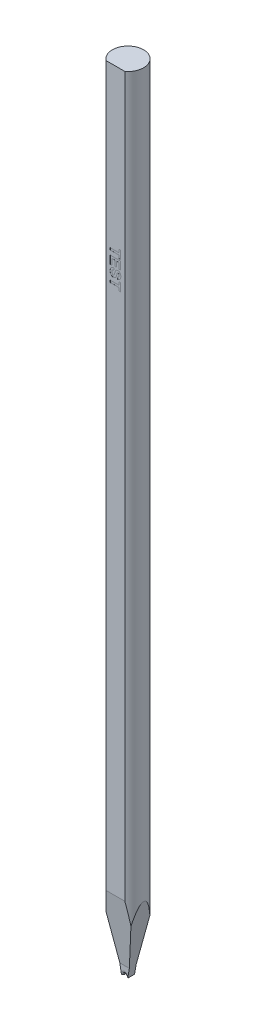
from build123d import *

# Parameters (mm, degrees)
SKETCH_TL_CUTTING_R       = 1.4986
TL_CUTTING_DEPTH          = 75.9968
SKETCH_TDF_GRINDING_W     = 3.0172
SKETCH_TDF_GRINDING_H     = 3.0172
TDF_GRINDING_DEPTH        = 76.9968
ENGRAVING_DEPTH           = 0.005
VW_VR_GRINDING_DEPTH      = 1.5086
VW_VR_GRINDING_DEPTH_BACK = 1.5086
ISA_GRINDING_DEPTH        = 1.5086
ISA_GRINDING_DEPTH_BACK   = 1.5086
SKETCH_PRE_FRX_BRX_W      = 1.18348
SKETCH_PRE_FRX_BRX_H      = 0.889
PRE_FRX_BRX_DEPTH         = 1.5086
PRE_FRX_BRX_DEPTH_BACK    = 1.5086
FR_EDM_R                  = 0.22606
BR_EDM_R                  = 0.22606
FA_BA_GRINDING_DEPTH      = 1.5086
FA_BA_GRINDING_DEPTH_BACK = 1.5086


with BuildPart() as part:
    # sketch_TL_cutting → TL_cutting (new body)
    with BuildSketch(Plane(origin=(0, 0, 0), x_dir=(1, 0, 0), z_dir=(0, 1, 0))):
        Circle(SKETCH_TL_CUTTING_R)
    extrude(amount=TL_CUTTING_DEPTH)

    # sketch_TDF_grinding → TDF_grinding (cut, through all)
    with BuildSketch(Plane(origin=(0, 0, 0), x_dir=(1, 0, 0), z_dir=(0, 1, 0))):
        with Locations((0, -2.71002)):
            Rectangle(SKETCH_TDF_GRINDING_W, SKETCH_TDF_GRINDING_H)
    extrude(amount=TDF_GRINDING_DEPTH, mode=Mode.SUBTRACT)

    # sketch_engraving → engraving (cut)
    with BuildSketch(Plane.XY.offset(1.20142)):
        Polygon((-0.5, 60.663467), (0.333333, 60.663467), (0.333333, 60.958338), (0.5, 60.958338), (0.5, 60.176287), (0.333333, 60.176287), (0.333333, 60.471159), (-0.5, 60.471159), align=None)
        Polygon((-0.5, 60.048082), (0.5, 60.048082), (0.5, 59.304492), (0.333333, 59.304492), (0.333333, 59.855774), (0.115385, 59.855774), (0.115385, 59.342954), (-0.051282, 59.342954), (-0.051282, 59.855774), (-0.333333, 59.855774), (-0.333333, 59.291672), (-0.5, 59.291672), align=None)
        with BuildLine():
            Line((-0.166667, 59.176287), (-0.153846, 58.983979))
            add(Edge.make_bspline(
                [(-0.153846, 58.983979), (-0.161891, 58.982447), (-0.177518, 58.97947), (-0.199795, 58.972866), (-0.220542, 58.96556), (-0.239663, 58.956947), (-0.257106, 58.947082), (-0.273157, 58.936291), (-0.287328, 58.924049), (-0.299925, 58.910717), (-0.310783, 58.896144), (-0.320246, 58.880443), (-0.328256, 58.863522), (-0.334922, 58.845445), (-0.339885, 58.826031), (-0.34342, 58.805464), (-0.345683, 58.783709), (-0.345994, 58.768841), (-0.346154, 58.761223)],
                knots=[0, 0, 0, 0, 2.5e-05, 4.8e-05, 7e-05, 9.1e-05, 0.000111, 0.00013, 0.000148, 0.000167, 0.000185, 0.000203, 0.000221, 0.000241, 0.000261, 0.000281, 0.000303, 0.000326, 0.000326, 0.000326, 0.000326], degree=3))
            add(Edge.make_bspline(
                [(-0.346154, 58.761223), (-0.346066, 58.753205), (-0.345896, 58.737609), (-0.343785, 58.715008), (-0.340761, 58.693876), (-0.335974, 58.674398), (-0.330621, 58.656212), (-0.323297, 58.639767), (-0.314849, 58.624799), (-0.305264, 58.611347), (-0.294632, 58.599606), (-0.283534, 58.589335), (-0.272208, 58.58039), (-0.260151, 58.573349), (-0.247852, 58.567651), (-0.234944, 58.563885), (-0.221722, 58.561341), (-0.212686, 58.56105), (-0.208133, 58.560903)],
                knots=[0, 0, 0, 0, 2.4e-05, 4.7e-05, 6.8e-05, 8.8e-05, 0.000107, 0.000125, 0.000142, 0.000158, 0.000174, 0.000189, 0.000204, 0.000217, 0.000231, 0.000244, 0.000258, 0.000271, 0.000271, 0.000271, 0.000271], degree=3))
            add(Edge.make_bspline(
                [(-0.208133, 58.560903), (-0.202439, 58.561197), (-0.191321, 58.561771), (-0.175221, 58.565542), (-0.160659, 58.572346), (-0.147071, 58.581583), (-0.134927, 58.594547), (-0.12346, 58.610951), (-0.113169, 58.631411), (-0.107424, 58.64658), (-0.104367, 58.654653)],
                knots=[0, 0, 0, 0, 1.7e-05, 3.3e-05, 4.9e-05, 6.5e-05, 8.2e-05, 0.000102, 0.000125, 0.000151, 0.000151, 0.000151, 0.000151], degree=3))
            add(Edge.make_bspline(
                [(-0.104367, 58.654653), (-0.103206, 58.658117), (-0.100608, 58.665869), (-0.096897, 58.679095), (-0.092218, 58.69508), (-0.087053, 58.713974), (-0.081545, 58.735737), (-0.074956, 58.760162), (-0.068334, 58.787622), (-0.063456, 58.806835), (-0.060897, 58.816912)],
                knots=[0, 0, 0, 0, 1.1e-05, 2.5e-05, 4.1e-05, 6.1e-05, 8.3e-05, 0.000109, 0.000137, 0.000168, 0.000168, 0.000168, 0.000168], degree=3))
            add(Edge.make_bspline(
                [(-0.060897, 58.816912), (-0.057621, 58.830036), (-0.051299, 58.855355), (-0.040053, 58.891467), (-0.02888, 58.924727), (-0.016756, 58.954814), (-0.004503, 58.98206), (0.008738, 59.006026), (0.02228, 59.02721), (0.032402, 59.039554), (0.03726, 59.045478)],
                knots=[0, 0, 0, 0, 4.1e-05, 7.8e-05, 0.000113, 0.000146, 0.000176, 0.000203, 0.000228, 0.000251, 0.000251, 0.000251, 0.000251], degree=3))
            add(Edge.make_bspline(
                [(0.03726, 59.045478), (0.044138, 59.052824), (0.057623, 59.067227), (0.079781, 59.086185), (0.103188, 59.102116), (0.127671, 59.115229), (0.15337, 59.125325), (0.180114, 59.132481), (0.207972, 59.137113), (0.226945, 59.137586), (0.236579, 59.137826)],
                knots=[0, 0, 0, 0, 3e-05, 5.9e-05, 8.7e-05, 0.000115, 0.000142, 0.00017, 0.000198, 0.000227, 0.000227, 0.000227, 0.000227], degree=3))
            add(Edge.make_bspline(
                [(0.236579, 59.137826), (0.249045, 59.137358), (0.273774, 59.136431), (0.310123, 59.127929), (0.345194, 59.11468), (0.373053, 59.099328), (0.394102, 59.084549), (0.409316, 59.072323), (0.423235, 59.058633), (0.436363, 59.043971), (0.448421, 59.028092), (0.459337, 59.010976), (0.469762, 58.992944), (0.481724, 58.966632), (0.494502, 58.931101), (0.505217, 58.884866), (0.51162, 58.83452), (0.512411, 58.799571), (0.512821, 58.781455)],
                knots=[0, 0, 0, 0, 3.7e-05, 7.4e-05, 0.000111, 0.00015, 0.000169, 0.000188, 0.000208, 0.000228, 0.000247, 0.000268, 0.000288, 0.00031, 0.000354, 0.000402, 0.000452, 0.000506, 0.000506, 0.000506, 0.000506], degree=3))
            add(Edge.make_bspline(
                [(0.512821, 58.781455), (0.512623, 58.766622), (0.512239, 58.737772), (0.508327, 58.695955), (0.502301, 58.656946), (0.493472, 58.620811), (0.482081, 58.587482), (0.468308, 58.556893), (0.452029, 58.529125), (0.433078, 58.504473), (0.412189, 58.48251), (0.389372, 58.463351), (0.364915, 58.446922), (0.338835, 58.433118), (0.311, 58.422277), (0.281444, 58.414315), (0.250236, 58.409049), (0.228852, 58.407729), (0.217949, 58.407056)],
                knots=[0, 0, 0, 0, 4.4e-05, 8.7e-05, 0.000126, 0.000163, 0.000198, 0.000231, 0.000263, 0.000294, 0.000324, 0.000354, 0.000383, 0.000413, 0.000442, 0.000473, 0.000504, 0.000537, 0.000537, 0.000537, 0.000537], degree=3))
            Line((0.217949, 58.407056), (0.205128, 58.599364))
            add(Edge.make_bspline(
                [(0.205128, 58.599364), (0.211159, 58.600473), (0.222912, 58.602634), (0.23974, 58.607341), (0.255319, 58.612622), (0.26955, 58.618888), (0.282453, 58.626107), (0.294054, 58.634311), (0.304443, 58.643347), (0.313349, 58.653595), (0.321255, 58.664819), (0.32777, 58.677446), (0.333733, 58.691084), (0.338229, 58.706245), (0.341792, 58.722654), (0.344434, 58.740315), (0.345724, 58.759268), (0.346007, 58.772306), (0.346154, 58.779052)],
                knots=[0, 0, 0, 0, 1.8e-05, 3.6e-05, 5.2e-05, 6.8e-05, 8.2e-05, 9.7e-05, 0.00011, 0.000124, 0.000137, 0.000151, 0.000166, 0.000182, 0.000199, 0.000217, 0.000235, 0.000256, 0.000256, 0.000256, 0.000256], degree=3))
            add(Edge.make_bspline(
                [(0.346154, 58.779052), (0.346025, 58.786065), (0.345773, 58.799711), (0.344229, 58.819595), (0.341378, 58.838249), (0.337667, 58.855763), (0.332619, 58.872113), (0.326463, 58.887266), (0.319216, 58.901291), (0.313514, 58.909842), (0.310697, 58.914068)],
                knots=[0, 0, 0, 0, 2.1e-05, 4.1e-05, 6e-05, 7.8e-05, 9.5e-05, 0.000111, 0.000127, 0.000142, 0.000142, 0.000142, 0.000142], degree=3))
            add(Edge.make_bspline(
                [(0.310697, 58.914068), (0.306849, 58.918903), (0.299396, 58.928268), (0.284597, 58.938346), (0.267882, 58.944413), (0.256061, 58.945143), (0.25, 58.945518)],
                knots=[0, 0, 0, 0, 1.8e-05, 3.6e-05, 5.3e-05, 7.1e-05, 7.1e-05, 7.1e-05, 7.1e-05], degree=3))
            add(Edge.make_bspline(
                [(0.25, 58.945518), (0.244335, 58.945212), (0.233176, 58.944608), (0.217325, 58.938524), (0.202638, 58.929166), (0.19466, 58.920423), (0.190505, 58.915871)],
                knots=[0, 0, 0, 0, 1.7e-05, 3.3e-05, 5e-05, 6.9e-05, 6.9e-05, 6.9e-05, 6.9e-05], degree=3))
            add(Edge.make_bspline(
                [(0.190505, 58.915871), (0.187808, 58.912257), (0.181782, 58.904183), (0.174123, 58.889393), (0.165827, 58.87154), (0.157718, 58.850219), (0.149623, 58.82557), (0.141171, 58.797593), (0.132606, 58.76627), (0.124311, 58.732399), (0.116157, 58.69801), (0.107243, 58.665194), (0.098552, 58.63468), (0.089443, 58.606609), (0.080575, 58.580837), (0.071467, 58.557488), (0.062597, 58.536404), (0.0504, 58.511816), (0.033879, 58.483949), (0.009862, 58.454741), (-0.017134, 58.42891), (-0.042589, 58.410912), (-0.064481, 58.398548), (-0.081932, 58.390587), (-0.100321, 58.3837), (-0.119668, 58.378094), (-0.14, 58.374031), (-0.161163, 58.370669), (-0.183331, 58.368951), (-0.198448, 58.368715), (-0.20613, 58.368595)],
                knots=[0, 0, 0, 0, 1.4e-05, 3e-05, 5e-05, 7.3e-05, 9.9e-05, 0.000128, 0.00016, 0.000196, 0.000232, 0.000266, 0.000298, 0.000327, 0.000355, 0.00038, 0.000403, 0.000423, 0.000462, 0.000499, 0.000536, 0.000574, 0.000593, 0.000612, 0.000631, 0.000652, 0.000672, 0.000693, 0.000716, 0.000739, 0.000739, 0.000739, 0.000739], degree=3))
            add(Edge.make_bspline(
                [(-0.20613, 58.368595), (-0.213214, 58.36876), (-0.227282, 58.369088), (-0.248162, 58.371378), (-0.268672, 58.37492), (-0.288836, 58.380163), (-0.308616, 58.387118), (-0.328297, 58.39495), (-0.347449, 58.404742), (-0.366088, 58.415888), (-0.384202, 58.428181), (-0.400907, 58.442114), (-0.416781, 58.456856), (-0.43083, 58.473361), (-0.4445, 58.490444), (-0.456414, 58.50922), (-0.467267, 58.529089), (-0.476944, 58.550231), (-0.485241, 58.572716), (-0.49276, 58.59641), (-0.498862, 58.621535), (-0.504103, 58.647922), (-0.508085, 58.675673), (-0.510867, 58.704751), (-0.512435, 58.735164), (-0.51269, 58.755879), (-0.512821, 58.766431)],
                knots=[0, 0, 0, 0, 2.1e-05, 4.2e-05, 6.3e-05, 8.4e-05, 0.000105, 0.000126, 0.000147, 0.000169, 0.000191, 0.000213, 0.000234, 0.000256, 0.000278, 0.0003, 0.000322, 0.000346, 0.00037, 0.000394, 0.00042, 0.000447, 0.000475, 0.000504, 0.000535, 0.000566, 0.000566, 0.000566, 0.000566], degree=3))
            add(Edge.make_bspline(
                [(-0.512821, 58.766431), (-0.512572, 58.781667), (-0.512087, 58.811331), (-0.507753, 58.854427), (-0.501118, 58.894848), (-0.491488, 58.932528), (-0.479126, 58.967514), (-0.463898, 58.99979), (-0.445714, 59.029198), (-0.425016, 59.056107), (-0.401421, 59.080146), (-0.375438, 59.101792), (-0.346734, 59.120625), (-0.315677, 59.137155), (-0.28186, 59.150643), (-0.24584, 59.162171), (-0.207126, 59.170748), (-0.180386, 59.174409), (-0.166667, 59.176287)],
                knots=[0, 0, 0, 0, 4.6e-05, 8.9e-05, 0.00013, 0.000168, 0.000205, 0.000241, 0.000275, 0.000309, 0.000343, 0.000376, 0.00041, 0.000445, 0.000482, 0.000519, 0.000559, 0.0006, 0.0006, 0.0006, 0.0006], degree=3))
        make_face()
        Polygon((-0.5, 57.971159), (0.333333, 57.971159), (0.333333, 58.266031), (0.5, 58.266031), (0.5, 57.483979), (0.333333, 57.483979), (0.333333, 57.778851), (-0.5, 57.778851), align=None)
    extrude(amount=-ENGRAVING_DEPTH, mode=Mode.SUBTRACT)

    # sketch_VW_VR_grinding → VW_VR_grinding (cut, two sides)
    with BuildSketch(Plane.XY) as vw_vr_grinding_sk:
        with BuildLine():
            Line((-1.4936, -0.01), (-1.4936, 0.874))
            ThreePointArc((-1.4936, 0.874), (-1.495064, 0.877536), (-1.4986, 0.879))
            Line((-1.4986, 0.879), (-1.5086, 0.879))
            Line((-1.5086, 0.879), (-1.5086, -0.01))
            Line((-1.5086, -0.01), (-1.4936, -0.01))
        make_face()
        with BuildLine():
            Line((1.4936, -0.01), (1.4936, 0.874))
            ThreePointArc((1.4936, 0.874), (1.495064, 0.877536), (1.4986, 0.879))
            Line((1.4986, 0.879), (1.5086, 0.879))
            Line((1.5086, 0.879), (1.5086, -0.01))
            Line((1.5086, -0.01), (1.4936, -0.01))
        make_face()
    extrude(amount=VW_VR_GRINDING_DEPTH, mode=Mode.SUBTRACT)
    extrude(vw_vr_grinding_sk.sketch, amount=-VW_VR_GRINDING_DEPTH_BACK, mode=Mode.SUBTRACT)

    # sketch_ISA_grinding → ISA_grinding (cut, two sides)
    with BuildSketch(Plane.XY) as isa_grinding_sk:
        Polygon((-0.29972, 0), (-1.5086, 6.855899), (-1.5086, -0.01), (1.5086, -0.01), (1.5086, 6.855899), (0.29972, 0), align=None)
    extrude(amount=ISA_GRINDING_DEPTH, mode=Mode.SUBTRACT)
    extrude(isa_grinding_sk.sketch, amount=-ISA_GRINDING_DEPTH_BACK, mode=Mode.SUBTRACT)

    # sketch_pre_FRX_BRX → pre_FRX_BRX (cut, two sides)
    with BuildSketch(Plane(origin=(0, 0, 0), x_dir=(0, 0, -1), z_dir=(1, 0, 0))) as pre_frx_brx_sk:
        with Locations((-0.91686, 0.4345)):
            Rectangle(SKETCH_PRE_FRX_BRX_W, SKETCH_PRE_FRX_BRX_H)
        with Locations((0.91686, 0.4345)):
            Rectangle(SKETCH_PRE_FRX_BRX_W, SKETCH_PRE_FRX_BRX_H)
    extrude(amount=PRE_FRX_BRX_DEPTH, mode=Mode.SUBTRACT)
    extrude(pre_frx_brx_sk.sketch, amount=-PRE_FRX_BRX_DEPTH_BACK, mode=Mode.SUBTRACT)

    # V-Groove_EDM: sweep along a path in sketch_contour_V-Groove
    with BuildLine(Plane(origin=(0, 0, 0), x_dir=(0, 0, -1), z_dir=(1, 0, 0))) as v_groove_edm_path:
        Line((-1.20142, 0.1905), (0, 0.1905))
        Line((0, 0.1905), (1.4986, 0.1905))
    # sketch_section_V-Groove → V-Groove_EDM (sweep, cut)
    with BuildSketch(Plane.XY.offset(1.20142)):
        with BuildLine():
            Line((-1.498995, -1.905), (-0.049899, 0.164524))
            ThreePointArc((-0.049899, 0.164524), (0, 0.1905), (0.049899, 0.164524))
            Line((0.049899, 0.164524), (1.498995, -1.905))
            Line((1.498995, -1.905), (-1.498995, -1.905))
        make_face()
    sweep(path=v_groove_edm_path.line, mode=Mode.SUBTRACT)

    # FR_EDM
    fr_edm_edges = [part.edges().sort_by_distance(p)[0] for p in [
        (0.107499, 0.082262, 0.32512),
        (0, 0.1905, 0.32512),
        (-0.107499, 0.082262, 0.32512),
    ]]
    fillet(fr_edm_edges, radius=FR_EDM_R)

    # BR_EDM
    br_edm_edges = [part.edges().sort_by_distance(p)[0] for p in [
        (0.107499, 0.082262, -0.32512),
        (0, 0.1905, -0.32512),
        (-0.107499, 0.082262, -0.32512),
    ]]
    fillet(br_edm_edges, radius=BR_EDM_R)

    # sketch_FA_BA_grinding → FA_BA_grinding (cut, two sides)
    with BuildSketch(Plane(origin=(0, 0, 0), x_dir=(0, 0, -1), z_dir=(1, 0, 0))) as fa_ba_grinding_sk:
        Polygon((2.4986, 16.354114), (2.4986, -0.1), (0.32512, -0.1), (0.32512, 0.889), align=None)
        Polygon((-3.272829, 21.863037), (-0.32512, 0.889), (-0.32512, -0.1), (-3.272829, -0.1), align=None)
    extrude(amount=FA_BA_GRINDING_DEPTH, mode=Mode.SUBTRACT)
    extrude(fa_ba_grinding_sk.sketch, amount=-FA_BA_GRINDING_DEPTH_BACK, mode=Mode.SUBTRACT)


solid = part.part
